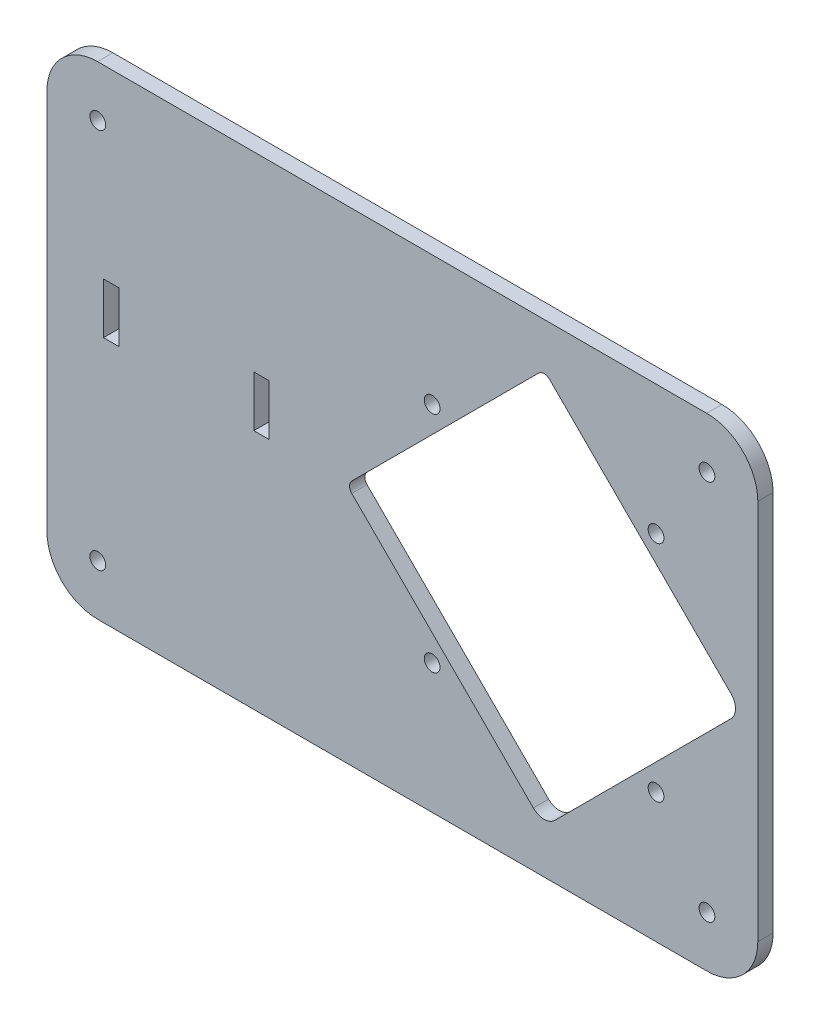
from build123d import *

# Parameters (mm, degrees)
MODEL_R             = 1.550000002
MODEL_R_2           = 1.550000003
MODEL_R_3           = 1.55
MODEL_W             = 3
MODEL_H             = 10
BOSS_EXTRUDE1_DEPTH = 3


with BuildPart() as part:
    # Model → Boss-Extrude1 (new body)
    with BuildSketch(Plane.XY):
        with BuildLine():
            Line((15.694779571, -8.847330863), (135.394779571, -8.847330863))
            ThreePointArc((135.394779571, -8.847330863), (142.465847383, -5.918398675), (145.394779571, 1.152669137))
            Line((145.394779571, 1.152669137), (145.394779571, 76.099977642))
            ThreePointArc((145.394779571, 76.099977642), (142.435982738, 83.158675114), (135.352544586, 86.057742657))
            Line((135.352544586, 86.057742657), (15.652444586, 86.057742657))
            ThreePointArc((15.652444586, 86.057742657), (8.623648393, 83.128873835), (5.694779571, 76.100077642))
            Line((5.694779571, 76.100077642), (5.694779571, 1.152669137))
            ThreePointArc((5.694779571, 1.152669137), (8.623711759, -5.918398675), (15.694779571, -8.847330863))
        make_face()
        with Locations((81.394879569, 16.599999996)):
            Circle(MODEL_R, mode=Mode.SUBTRACT)
        with Locations((81.394729575, 60.600050002)):
            Circle(MODEL_R, mode=Mode.SUBTRACT)
        with Locations((125.394779569, 16.6)):
            Circle(MODEL_R, mode=Mode.SUBTRACT)
        with Locations((125.394879569, 60.599999996)):
            Circle(MODEL_R, mode=Mode.SUBTRACT)
        with Locations((135.394779571, 76.057742657)):
            Circle(MODEL_R_2, mode=Mode.SUBTRACT)
        with Locations((135.394779571, 1.152669137)):
            Circle(MODEL_R_2, mode=Mode.SUBTRACT)
        with Locations((15.694779571, 76.057742657)):
            Circle(MODEL_R_2, mode=Mode.SUBTRACT)
        with Locations((15.694779571, 1.152669137)):
            Circle(MODEL_R_3, mode=Mode.SUBTRACT)
        with BuildLine():
            Line((101.273453006, 1.866320938), (65.600147072, 37.539741531))
            ThreePointArc((65.600147072, 37.539741531), (65.160808948, 38.600399998), (65.600147072, 39.661058465))
            Line((65.600147072, 39.661058465), (102.334113177, 76.395142639))
            ThreePointArc((102.334113177, 76.395142639), (103.394773848, 76.834484172), (104.455435225, 76.395144343))
            Line((104.455435225, 76.395144343), (140.128859227, 40.721720342))
            ThreePointArc((140.128859227, 40.721720342), (141.007538884, 38.600399998), (140.128859227, 36.479079655))
            Line((140.128859227, 36.479079655), (105.516097102, 1.866317529))
            ThreePointArc((105.516097102, 1.866317529), (103.394774348, 0.987637873), (101.273453006, 1.866320938))
        make_face(mode=Mode.SUBTRACT)
        with Locations((18.315849629, 44.661058465)):
            Rectangle(MODEL_W, MODEL_H, mode=Mode.SUBTRACT)
        with Locations((47.848560539, 43.600399998)):
            Rectangle(MODEL_W, MODEL_H, mode=Mode.SUBTRACT)
    extrude(amount=BOSS_EXTRUDE1_DEPTH)


solid = part.part
